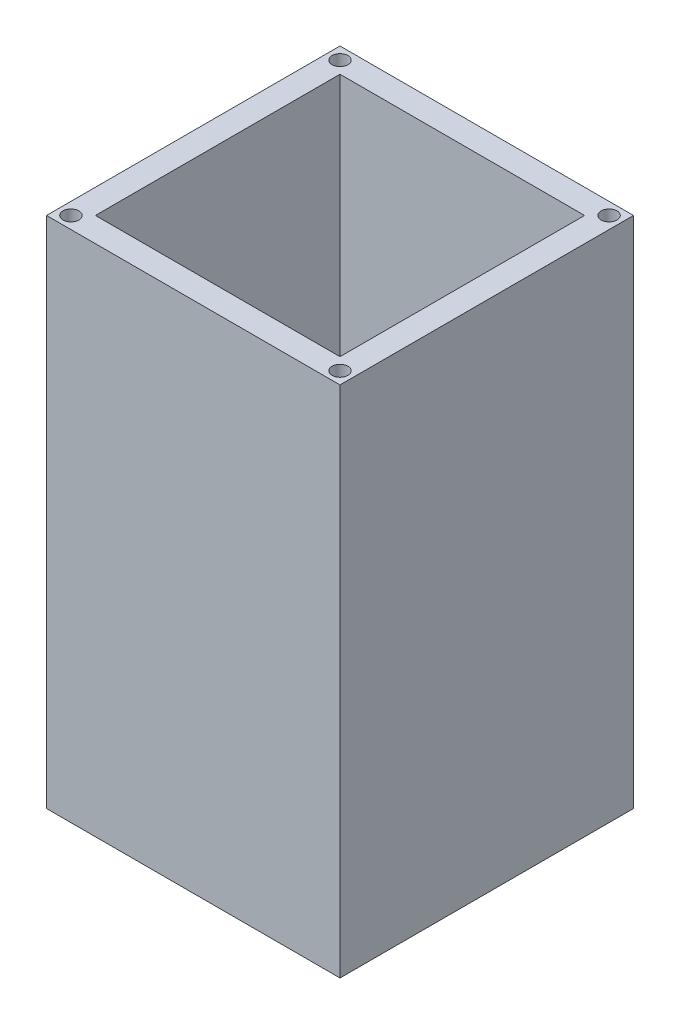
from build123d import *

# Parameters (mm, degrees)
SKETCH1_W           = 120
SKETCH1_H           = 120
SKETCH1_R           = 7.5
BOSS_EXTRUDE1_DEPTH = 10
BOSS_EXTRUDE2_DEPTH = 200
SKETCH2_R           = 3.25
CUT_EXTRUDE1_DEPTH  = 15


with BuildPart() as part:
    # Sketch1 → Boss-Extrude1 (new body)
    with BuildSketch(Plane(origin=(0, 0, 0), x_dir=(1, 0, 0), z_dir=(0, 1, 0))):
        with Locations((60, 60)):
            Rectangle(SKETCH1_W, SKETCH1_H)
        with Locations(Location((60, 60, 0), (0, 0, 270))):
            Circle(SKETCH1_R, mode=Mode.SUBTRACT)
    extrude(amount=BOSS_EXTRUDE1_DEPTH)

    # 3DSketch1 → Boss-Extrude2 (add)
    with BuildSketch(Plane(origin=(110, 10, -10), x_dir=(-0.7071067811865477, 0, -0.7071067811865475), z_dir=(0, 1, 0))):
        Polygon((155.563491861, 0), (70.710678119, 84.852813742), (-14.142135624, 0), (70.710678119, -84.852813742), align=None)
        Polygon((0, 0), (70.710678119, -70.710678119), (141.421356237, 0), (70.710678119, 70.710678119), align=None, mode=Mode.SUBTRACT)
    extrude(amount=BOSS_EXTRUDE2_DEPTH)

    # Sketch2 → Cut-Extrude1 (cut)
    with BuildSketch(Plane(origin=(0, 210, 0), x_dir=(1, 0, 0), z_dir=(0, 1, 0))):
        with Locations(Location((115, 115, 0), (0, 0, 270))):
            Circle(SKETCH2_R)
        with Locations(Location((5, 115, 0), (0, 0, 270))):
            Circle(SKETCH2_R)
        with Locations(Location((115, 5, 0), (0, 0, 270))):
            Circle(SKETCH2_R)
        with Locations(Location((5, 5, 0), (0, 0, 270))):
            Circle(SKETCH2_R)
    extrude(amount=-CUT_EXTRUDE1_DEPTH, mode=Mode.SUBTRACT)


solid = part.part
